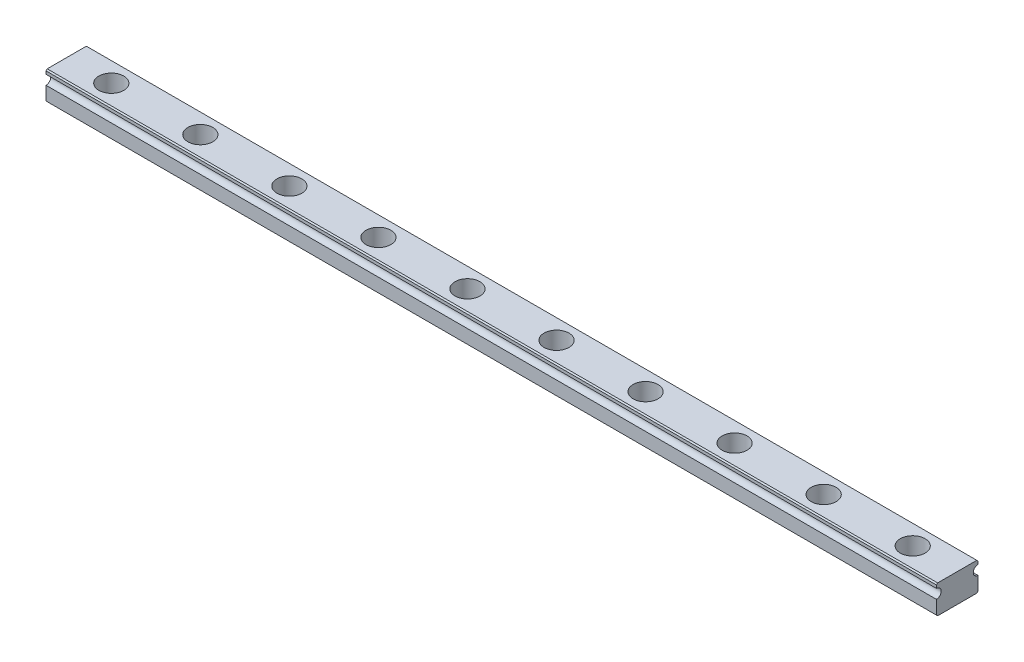
from build123d import *

# Parameters (mm, degrees)
RESSALTO_EXTRUS_O1_DEPTH = 75
CHANFRO1_SIZE            = 0.2
ESBO_O2_R                = 2.1
CORTE_EXTRUS_O1_DEPTH    = 150


with BuildPart() as part:
    # Esboço1 → Ressalto-extrusão1 (new body, symmetric)
    with BuildSketch(Plane(origin=(0, 0, 0), x_dir=(0, 0, -1), z_dir=(1, 0, 0))):
        with BuildLine():
            Line((-3.5, 0), (3.5, 0))
            Line((3.5, 0), (3.5, 2.5))
            ThreePointArc((3.5, 2.5), (2.7, 3.3), (3.5, 4.1))
            Line((3.5, 4.1), (3.5, 4.8))
            Line((3.5, 4.8), (-3.5, 4.8))
            Line((-3.5, 4.8), (-3.5, 4.1))
            ThreePointArc((-3.5, 4.1), (-2.7, 3.3), (-3.5, 2.5))
            Line((-3.5, 2.5), (-3.5, 0))
        make_face()
    extrude(amount=RESSALTO_EXTRUS_O1_DEPTH, both=True)

    # Chanfro1
    chanfro1_edges = [part.edges().sort_by_distance(p)[0] for p in [
        (0, 0, -3.5),
        (0, 0, 3.5),
        (0, 4.8, 3.5),
        (0, 4.8, -3.5),
    ]]
    chamfer(chanfro1_edges, length=CHANFRO1_SIZE)

    # Esboço2 → Corte-extrusão1 (cut)
    with BuildSketch(Plane(origin=(0, 4.8, 0), x_dir=(1, 0, 0), z_dir=(0, 1, 0))):
        with Locations((-7.5, 0)):
            Circle(ESBO_O2_R)
        with Locations((-22.5, 0)):
            Circle(ESBO_O2_R)
        with Locations((-37.5, 0)):
            Circle(ESBO_O2_R)
        with Locations((-52.5, 0)):
            Circle(ESBO_O2_R)
        with Locations((-67.5, 0)):
            Circle(ESBO_O2_R)
        with Locations((67.5, 0)):
            Circle(ESBO_O2_R)
        with Locations((52.5, 0)):
            Circle(ESBO_O2_R)
        with Locations((37.5, 0)):
            Circle(ESBO_O2_R)
        with Locations((22.5, 0)):
            Circle(ESBO_O2_R)
        with Locations((7.5, 0)):
            Circle(ESBO_O2_R)
    extrude(amount=-CORTE_EXTRUS_O1_DEPTH, mode=Mode.SUBTRACT)


solid = part.part
